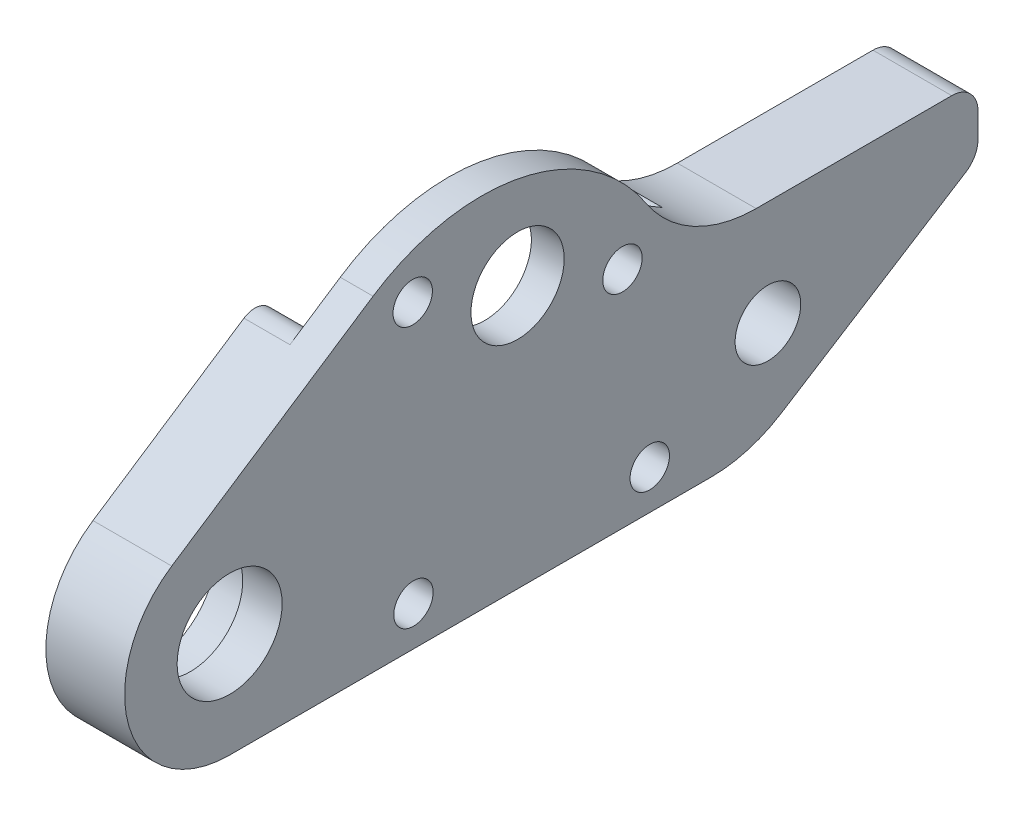
from build123d import *

# Parameters (mm, degrees)
SKETCH27_R          = 3.55
SKETCH27_R_2        = 4
SKETCH27_R_3        = 2.5
SKETCH27_R_4        = 1.5
BOSS_EXTRUDE1_DEPTH = 6
SKETCH47_R          = 4.99
CUT_EXTRUDE8_DEPTH  = 3
CUT_EXTRUDE10_DEPTH = 3.5
SKETCH49_W          = 24
SKETCH49_H          = 6
CUT_EXTRUDE11_DEPTH = 3
SKETCH50_R          = 1.5
CUT_EXTRUDE12_DEPTH = 3
FILLET1_R           = 3
CUT_EXTRUDE13_REACH = 5
SKETCH51_R          = 1.5
FILLET2_R           = 10
FILLET3_R           = 2


with BuildPart() as part:
    # Sketch27 → Boss-Extrude1 (new body)
    with BuildSketch(Plane(origin=(0, 0, 0), x_dir=(0, 0, -1), z_dir=(1, 0, 0))):
        with BuildLine():
            Line((4.589716929, 48.674533934), (19.924994259, 58.807513206))
            ThreePointArc((19.924994259, 58.807513206), (31.222626062, 60.983884909), (40.738603868, 54.517104832))
            ThreePointArc((40.738603868, 54.517104832), (44.34906679, 51.201450356), (49.101489768, 50))
            Line((49.101489768, 50), (66, 50))
            Line((66, 50), (66, 45))
            Line((66, 45), (48.564398788, 34))
            Line((48.564398788, 34), (9, 34))
            ThreePointArc((9, 34), (1.33852914, 39.697422256), (4.589716929, 48.674533934))
        make_face()
        with Locations((30.931712199, 54)):
            Circle(SKETCH27_R, mode=Mode.SUBTRACT)
        with Locations((9, 42)):
            Circle(SKETCH27_R_2, mode=Mode.SUBTRACT)
        with Locations((50, 42)):
            Circle(SKETCH27_R_3, mode=Mode.SUBTRACT)
        with Locations((38.919099476, 51.092828782)):
            Circle(SKETCH27_R_4, mode=Mode.SUBTRACT)
        with Locations((22.944324923, 56.907171218)):
            Circle(SKETCH27_R_4, mode=Mode.SUBTRACT)
    extrude(amount=BOSS_EXTRUDE1_DEPTH)

    # Sketch47 → Cut-Extrude8 (cut)
    with BuildSketch(Plane.ZY):
        with Locations((-9, 42)):
            Circle(SKETCH47_R)
    extrude(amount=-CUT_EXTRUDE8_DEPTH, mode=Mode.SUBTRACT)

    # Sketch48 → Cut-Extrude10 (cut)
    with BuildSketch(Plane.ZY):
        with BuildLine():
            Line((-45.322401917, 50.741571677), (-29.852897284, 65.367501227))
            Line((-29.852897284, 65.367501227), (-16.092106493, 56.274883933))
            ThreePointArc((-16.092106493, 56.274883933), (-17.677203396, 56.31769628), (-18.415049974, 54.914148092))
            ThreePointArc((-18.415049974, 54.914148092), (-28.514928411, 41.684901295), (-42.865524712, 50.115850296))
            ThreePointArc((-42.865524712, 50.115850296), (-43.921672049, 51.10520774), (-45.322401917, 50.741571677))
        make_face()
    extrude(amount=-CUT_EXTRUDE10_DEPTH, mode=Mode.SUBTRACT)

    # Sketch49 → Cut-Extrude11 (cut)
    with BuildSketch(Plane.ZY):
        with Locations((-32, 37)):
            Rectangle(SKETCH49_W, SKETCH49_H)
    extrude(amount=-CUT_EXTRUDE11_DEPTH, mode=Mode.SUBTRACT)

    # Sketch50 → Cut-Extrude12 (cut)
    with BuildSketch(Plane.ZY):
        with Locations((-43, 39)):
            Circle(SKETCH50_R)
        with Locations((-21, 39)):
            Circle(SKETCH50_R)
    extrude(amount=-CUT_EXTRUDE12_DEPTH, mode=Mode.SUBTRACT)

    # Fillet1
    fillet1_edges = [part.edges().sort_by_distance(p)[0] for p in [
        (1.5, 37.881966011, -44),
        (1.5, 40, -41.881966011),
        (1.5, 40, -22.118033989),
        (1.5, 37.881966011, -20),
    ]]
    fillet(fillet1_edges, radius=FILLET1_R)

    # Sketch51 → Cut-Extrude13 (cut, up to next)
    with BuildSketch(Plane.ZY.offset(-3), mode=Mode.PRIVATE) as cut_extrude13_sk1:
        with Locations((-41, 37)):
            Circle(SKETCH51_R)
    cut_extrude13_tool1 = extrude(cut_extrude13_sk1.sketch, amount=-CUT_EXTRUDE13_REACH, mode=Mode.PRIVATE) & part.part
    add(cut_extrude13_tool1.solids().sort_by_distance((3, 37, -41))[0], mode=Mode.SUBTRACT)
    # Sketch51 → Cut-Extrude13 (cut, up to next)
    with BuildSketch(Plane.ZY.offset(-3), mode=Mode.PRIVATE) as cut_extrude13_sk2:
        with Locations((-23, 37)):
            Circle(SKETCH51_R)
    cut_extrude13_tool2 = extrude(cut_extrude13_sk2.sketch, amount=-CUT_EXTRUDE13_REACH, mode=Mode.PRIVATE) & part.part
    add(cut_extrude13_tool2.solids().sort_by_distance((3, 37, -23))[0], mode=Mode.SUBTRACT)

    # Fillet2
    fillet2_edges = [part.edges().sort_by_distance(p)[0] for p in [
        (3, 34, -48.564398788),
    ]]
    fillet(fillet2_edges, radius=FILLET2_R)

    # Fillet3
    fillet3_edges = [part.edges().sort_by_distance(p)[0] for p in [
        (3, 50, -66),
        (3, 45, -66),
    ]]
    fillet(fillet3_edges, radius=FILLET3_R)


solid = part.part
